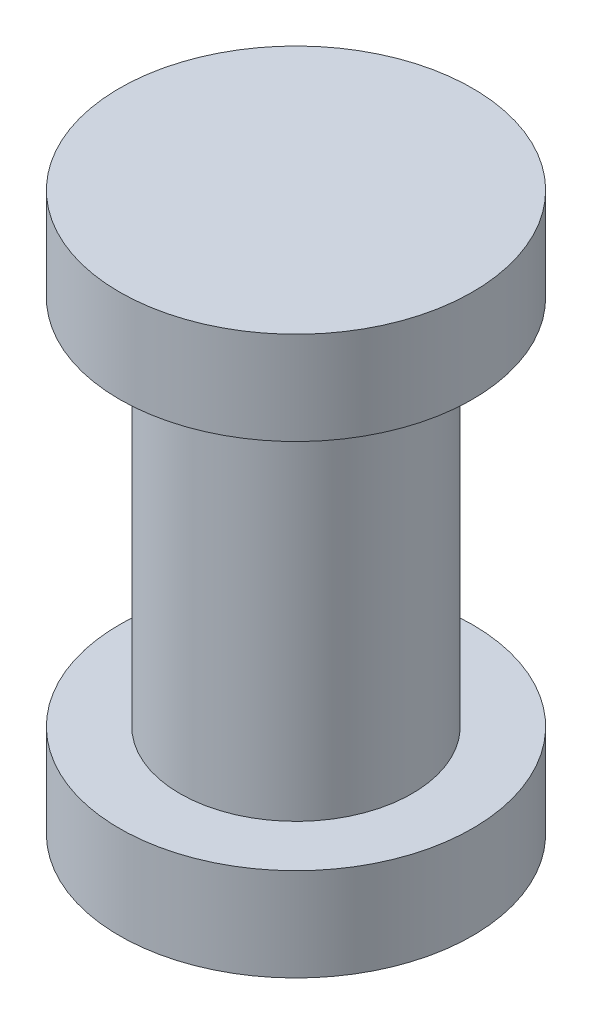
from build123d import *

# Parameters (mm, degrees)
SKETCH1_R           = 19
BOSS_EXTRUDE1_DEPTH = 10
SKETCH2_R           = 12.5
BOSS_EXTRUDE2_DEPTH = 50
SKETCH4_R           = 19
BOSS_EXTRUDE3_DEPTH = 10


with BuildPart() as part:
    # Sketch1 → Boss-Extrude1 (new body)
    with BuildSketch(Plane(origin=(0, 0, 0), x_dir=(1, 0, 0), z_dir=(0, 1, 0))):
        Circle(SKETCH1_R)
    extrude(amount=-BOSS_EXTRUDE1_DEPTH)

    # Sketch2 → Boss-Extrude2 (add)
    with BuildSketch(Plane.XZ.offset(10)):
        Circle(SKETCH2_R)
    extrude(amount=BOSS_EXTRUDE2_DEPTH)

    # Sketch4 → Boss-Extrude3 (add)
    with BuildSketch(Plane.XZ.offset(60)):
        Circle(SKETCH4_R)
    extrude(amount=-BOSS_EXTRUDE3_DEPTH)


solid = part.part
